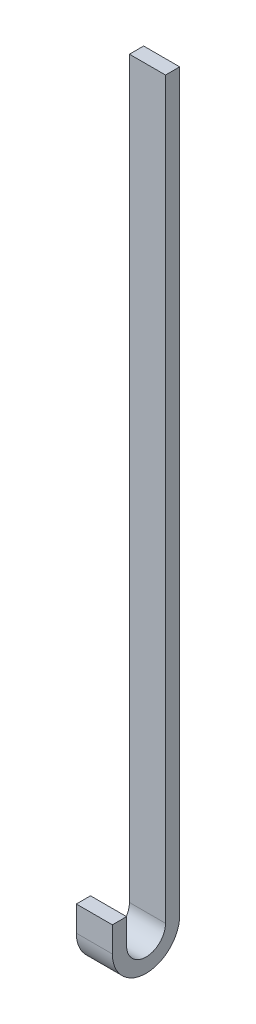
from build123d import *

# Parameters (mm, degrees)
BOSS_EXTRUDE1_DEPTH = 38.1


with BuildPart() as part:
    # Sketch1 → Boss-Extrude1 (new body)
    with BuildSketch(Plane(origin=(0, 0, 0), x_dir=(0, 0, -1), z_dir=(1, 0, 0))):
        with BuildLine():
            Line((0, 0), (0, -26.692482619))
            ThreePointArc((0, -26.692482619), (35.56, -62.252482619), (71.12, -26.692482619))
            Line((71.12, -26.692482619), (71.12, 749.3))
            Line((71.12, 749.3), (56.134, 749.3))
            Line((56.134, 749.3), (56.134, -26.692482619))
            ThreePointArc((56.134, -26.692482619), (35.56, -47.266482619), (14.986, -26.692482619))
            Line((14.986, -26.692482619), (14.986, 0))
            Line((14.986, 0), (0, 0))
        make_face()
    extrude(amount=BOSS_EXTRUDE1_DEPTH)


solid = part.part
